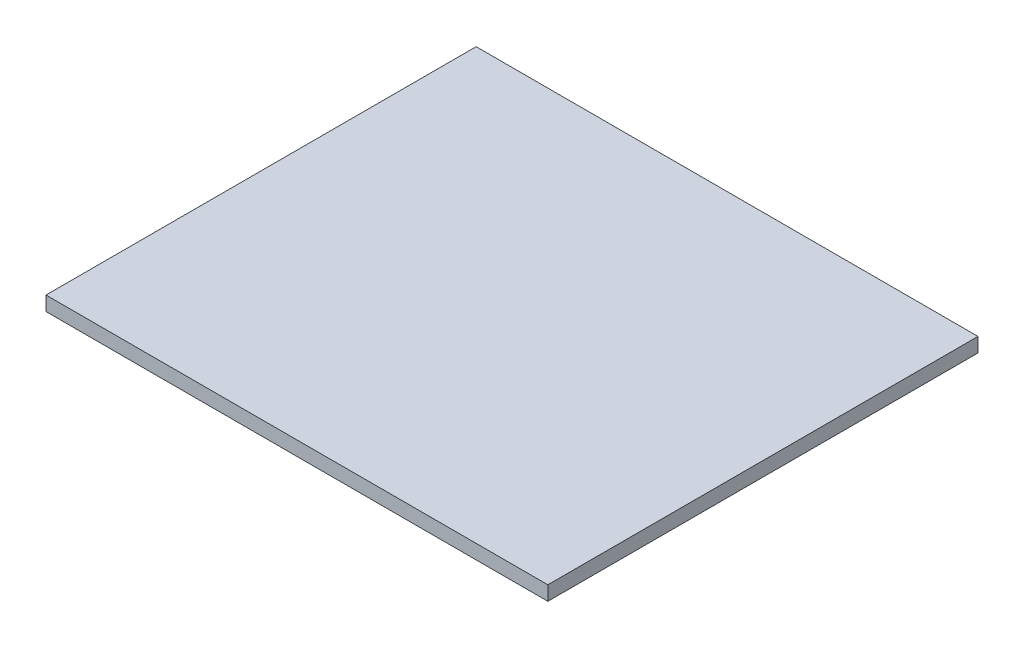
from build123d import *

# Parameters (mm, degrees)
SKETCH_1_W      = 56
SKETCH_1_H      = 48
EXTRUDE_1_DEPTH = 1.6


with BuildPart() as part:
    # Эскиз1 → Бобышка-Вытянуть1 (new body)
    with BuildSketch(Plane(origin=(0, 0, 0), x_dir=(1, 0, 0), z_dir=(0, 1, 0))):
        with Locations((-11.10654144, -0.240698632)):
            Rectangle(SKETCH_1_W, SKETCH_1_H)
    extrude(amount=EXTRUDE_1_DEPTH)


solid = part.part
